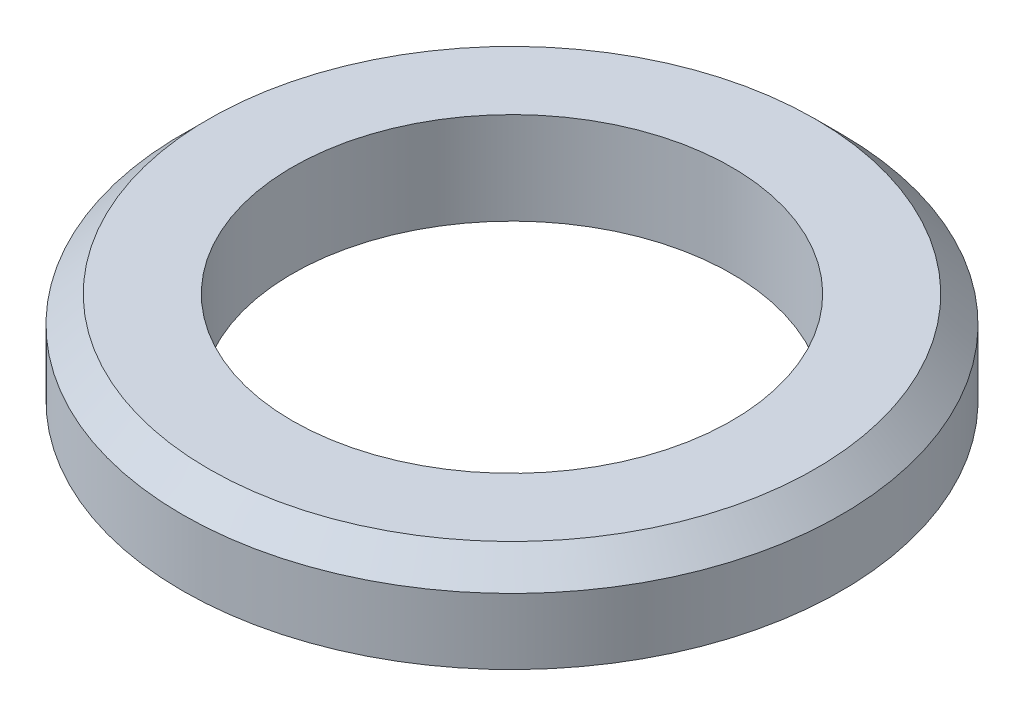
from build123d import *

# Parameters (mm, degrees)
SKETCH1_R           = 0.75
SKETCH1_R_2         = 0.5
BOSS_EXTRUDE1_DEPTH = 0.21
CHAMFER1_SIZE       = 0.06


with BuildPart() as part:
    # Sketch1 → Boss-Extrude1 (new body)
    with BuildSketch(Plane(origin=(0, 0, 0), x_dir=(1, 0, 0), z_dir=(0, 1, 0))):
        Circle(SKETCH1_R)
        Circle(SKETCH1_R_2, mode=Mode.SUBTRACT)
    extrude(amount=BOSS_EXTRUDE1_DEPTH)

    # Chamfer1
    chamfer1_edges = [part.edges().sort_by_distance(p)[0] for p in [
        (-0.75, 0.21, 0),
    ]]
    chamfer(chamfer1_edges, length=CHAMFER1_SIZE)


solid = part.part
